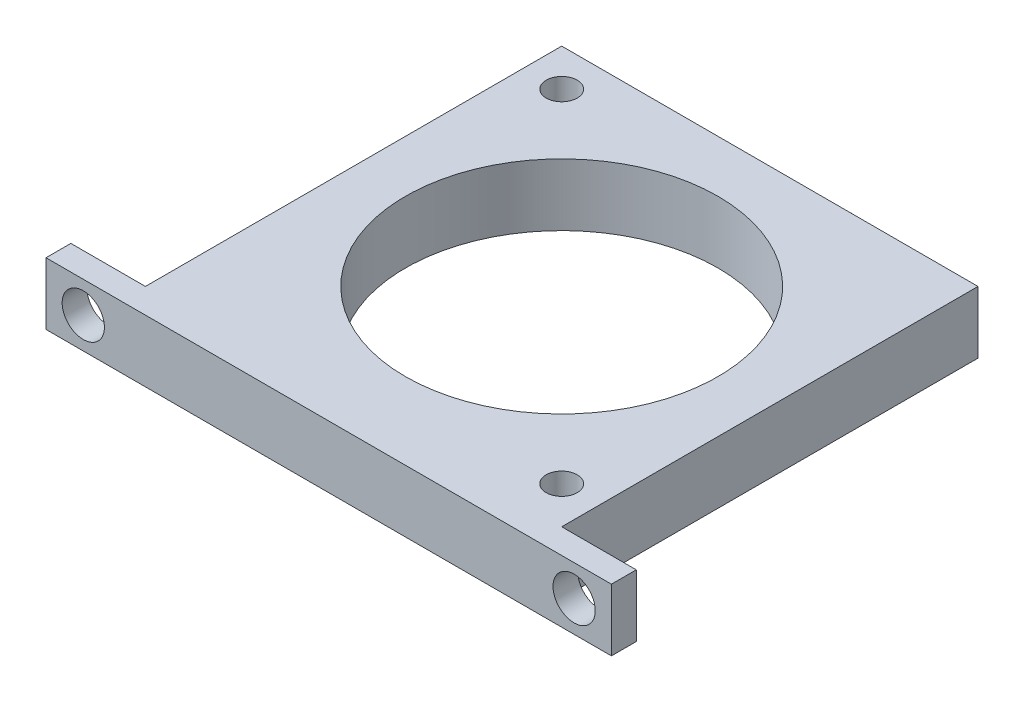
from build123d import *

# Parameters (mm, degrees)
SKETCH1_W                     = 33.5
SKETCH1_H                     = 33.5
BOSS_EXTRUDE1_DEPTH           = 70
M3X0_5_TAPPED_HOLE1_D         = 2.5
M3X0_5_TAPPED_HOLE1_DEPTH     = 7.62
M3X0_5_TAPPED_HOLE1_TIP       = 0.751075774
M3X0_5_TAPPED_HOLE2_D         = 2.5
M3X0_5_TAPPED_HOLE2_DEPTH     = 7.62
M3X0_5_TAPPED_HOLE2_TIP       = 0.751075774
SKETCH7_W                     = 6
SKETCH7_H                     = 50
BOSS_EXTRUDE2_DEPTH           = 3
SKETCH8_W                     = 6
SKETCH8_H                     = 50
BOSS_EXTRUDE3_DEPTH           = 3
SKETCH10_W                    = 1.7
SKETCH10_H                    = 33.5
M3_CLEARANCE_HOLE1_AT_2_COUNT = 2
M3_CLEARANCE_HOLE1_AT_2_PITCH = 25
M3_CLEARANCE_HOLE1_AT_3_COUNT = 2
M3_CLEARANCE_HOLE1_AT_3_PITCH = 39.5
M3_CLEARANCE_HOLE1_AT_4_COUNT = 2
M3_CLEARANCE_HOLE1_AT_4_PITCH = 46.746657635
SKETCH11_R                    = 12.573
CUT_EXTRUDE1_DEPTH            = 71
SKETCH12_W                    = 33.5
SKETCH12_H                    = 45
CUT_EXTRUDE2_DEPTH            = 32.5
SKETCH13_W                    = 45.5
SKETCH13_H                    = 70.777616709
CUT_EXTRUDE3_DEPTH            = 34.5
SKETCH14_W                    = 45.5
SKETCH14_H                    = 5
BOSS_EXTRUDE4_DEPTH           = 2
M3_CLEARANCE_HOLE2_D          = 3.4


with BuildPart() as part:
    # Sketch1 → Boss-Extrude1 (new body)
    with BuildSketch(Plane(origin=(0, 0, 0), x_dir=(1, 0, 0), z_dir=(0, 1, 0))):
        Rectangle(SKETCH1_W, SKETCH1_H)
    extrude(amount=BOSS_EXTRUDE1_DEPTH)

    # M3x0.5 Tapped Hole1
    with Locations(Plane(origin=(13.75, 70, 13.75), x_dir=(0, 0, 1), z_dir=(0, 1, 0))):
        with Locations((0, 0), (-27.5, -27.5)):
            Hole(M3X0_5_TAPPED_HOLE1_D / 2, depth=M3X0_5_TAPPED_HOLE1_DEPTH)
            with Locations((0, 0, -(M3X0_5_TAPPED_HOLE1_DEPTH + M3X0_5_TAPPED_HOLE1_TIP / 2))):  # 118° drill point
                Cone(0, M3X0_5_TAPPED_HOLE1_D / 2, M3X0_5_TAPPED_HOLE1_TIP, mode=Mode.SUBTRACT)

    # M3x0.5 Tapped Hole2
    with Locations(Plane(origin=(16.75, 6, 13.75), x_dir=(0, 0, 1), z_dir=(1, 0, 0))):
        with Locations((0, 0), (-27.5, 0)):
            Hole(M3X0_5_TAPPED_HOLE2_D / 2, depth=M3X0_5_TAPPED_HOLE2_DEPTH)
            with Locations((0, 0, -(M3X0_5_TAPPED_HOLE2_DEPTH + M3X0_5_TAPPED_HOLE2_TIP / 2))):  # 118° drill point
                Cone(0, M3X0_5_TAPPED_HOLE2_D / 2, M3X0_5_TAPPED_HOLE2_TIP, mode=Mode.SUBTRACT)

    # Sketch11 → Cut-Extrude1 (cut, through all)
    with BuildSketch(Plane.XZ):
        Circle(SKETCH11_R)
    extrude(amount=-CUT_EXTRUDE1_DEPTH, mode=Mode.SUBTRACT)

    # Sketch12 → Cut-Extrude2 (cut)
    with BuildSketch(Plane.XY.offset(16.75)):
        with Locations((0, 35.5)):
            Rectangle(SKETCH12_W, SKETCH12_H)
    extrude(amount=-CUT_EXTRUDE2_DEPTH, mode=Mode.SUBTRACT)


with BuildPart() as body_2:
    # Sketch7 → Boss-Extrude2 (new body)
    with BuildSketch(Plane(origin=(0, 0, -16.75), x_dir=(-1, 0, 0), z_dir=(0, 0, -1))):
        with Locations((-19.75, 36)):
            Rectangle(SKETCH7_W, SKETCH7_H)
    extrude(amount=-BOSS_EXTRUDE2_DEPTH)

    # Sketch10 → M3 Clearance Hole1 (revolve, cut)
    with BuildSketch(Plane(origin=(19.75, 51, -16.75), x_dir=(0, 1, 0), z_dir=(1, 0, 0))):
        with Locations((0.85, 16.75)):
            Rectangle(SKETCH10_W, SKETCH10_H)
    m3_clearance_hole1 = revolve(axis=Axis((19.75, 51, -23.1), (0, 0, 1)), mode=Mode.SUBTRACT)

    # M3 Clearance Hole1 at 2: M3 Clearance Hole1 ×2
    with Locations(*[(0, -i * M3_CLEARANCE_HOLE1_AT_2_PITCH, 0) for i in range(1, M3_CLEARANCE_HOLE1_AT_2_COUNT)]):
        add(m3_clearance_hole1, mode=Mode.SUBTRACT)


with BuildPart() as body_3:
    # Sketch8 → Boss-Extrude3 (new body)
    with BuildSketch(Plane(origin=(0, 0, -16.75), x_dir=(-1, 0, 0), z_dir=(0, 0, -1))):
        with Locations((19.75, 36)):
            Rectangle(SKETCH8_W, SKETCH8_H)
    extrude(amount=-BOSS_EXTRUDE3_DEPTH)

    # M3 Clearance Hole1 at 3: M3 Clearance Hole1 ×2
    with Locations(*[(-i * M3_CLEARANCE_HOLE1_AT_3_PITCH, 0, 0) for i in range(1, M3_CLEARANCE_HOLE1_AT_3_COUNT)]):
        add(m3_clearance_hole1, mode=Mode.SUBTRACT)

    # M3 Clearance Hole1 at 4: M3 Clearance Hole1 ×2
    with Locations(*[Vector(-0.844980197, -0.534797593, 0) * (i * M3_CLEARANCE_HOLE1_AT_4_PITCH) for i in range(1, M3_CLEARANCE_HOLE1_AT_4_COUNT)]):
        add(m3_clearance_hole1, mode=Mode.SUBTRACT)


with BuildPart() as cut_extrude3_tool:
    # Sketch13 → Cut-Extrude3 (new body, through all)
    with BuildSketch(Plane.XY.offset(16.75)):
        with Locations((0, 29.611191645)):
            Rectangle(SKETCH13_W, SKETCH13_H)
    extrude(amount=-CUT_EXTRUDE3_DEPTH)


with BuildPart() as part_1:
    add(part.part)

    # Cut-Extrude3: cut by cut_extrude3_tool
    add(cut_extrude3_tool.part, mode=Mode.SUBTRACT)

    # Sketch14 → Boss-Extrude4 (add)
    with BuildSketch(Plane.XY.offset(16.75)):
        with Locations((0, 67.5)):
            Rectangle(SKETCH14_W, SKETCH14_H)
    extrude(amount=BOSS_EXTRUDE4_DEPTH)

    # M3 Clearance Hole2 (through all)
    with Locations(Plane(origin=(-19.75, 67.5, 16.75), x_dir=(-1, 0, 0), z_dir=(0, 0, -1))):
        with Locations((0, 0), (-39.5, 0)):
            Hole(M3_CLEARANCE_HOLE2_D / 2)


with BuildPart() as body_2_1:
    add(body_2.part)

    # Cut-Extrude3: cut by cut_extrude3_tool
    add(cut_extrude3_tool.part, mode=Mode.SUBTRACT)


with BuildPart() as body_3_1:
    add(body_3.part)

    # Cut-Extrude3: cut by cut_extrude3_tool
    add(cut_extrude3_tool.part, mode=Mode.SUBTRACT)


solid = part_1.part
